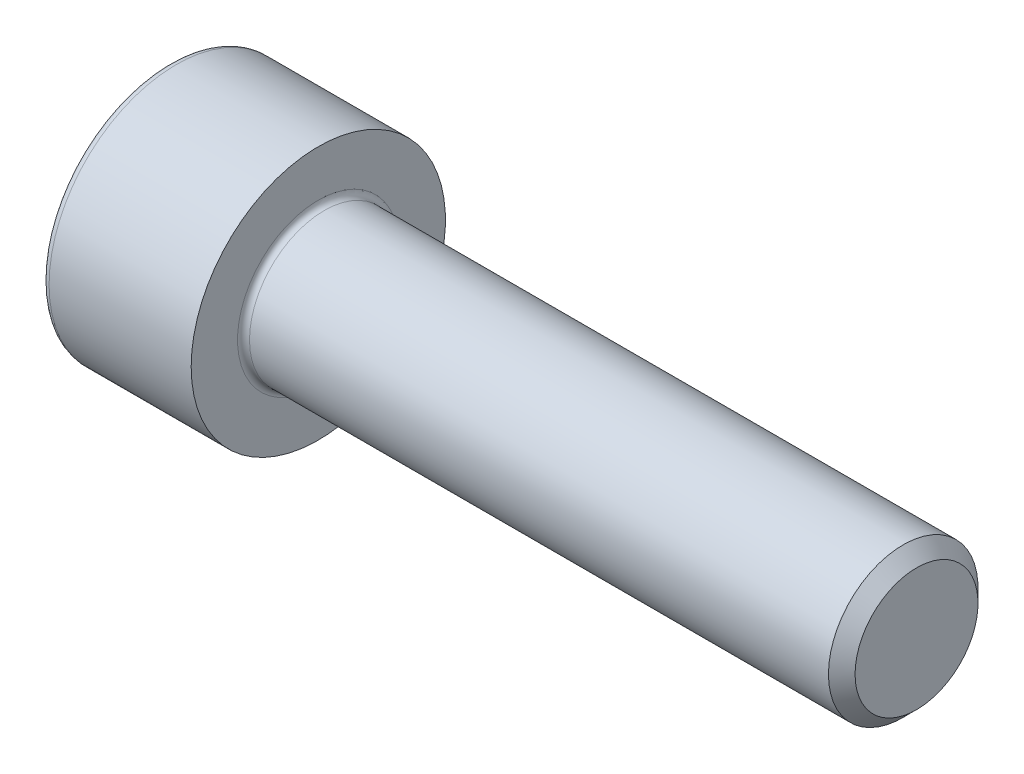
from build123d import *

# Parameters (mm, degrees)
FILLET1_R   = 0.2
FILLET2_R   = 0.25
HEX_2_DEPTH = 2.5


with BuildPart() as part:
    # BodySke → Base-Revolve (revolve)
    with BuildSketch(Plane.XY):
        Polygon((0, 0), (0, 4.25), (5, 4.25), (5, 2.5), (24.555, 2.5), (25, 2.055), (25, 0), align=None)
    revolve(axis=Axis((-31.75, 0, 0), (1, 0, 0)))

    # Fillet1
    fillet1_edges = [part.edges().sort_by_distance(p)[0] for p in [
        (5, -2.5, 0),
    ]]
    fillet(fillet1_edges, radius=FILLET1_R)

    # Fillet2
    fillet2_edges = [part.edges().sort_by_distance(p)[0] for p in [
        (0, -4.25, 0),
    ]]
    fillet(fillet2_edges, radius=FILLET2_R)

    # Sketch2 → Hex-PreBroach (revolve, cut)
    with BuildSketch(Plane.XY):
        Polygon((0, 2.042), (2.5, 2.042), (3.67894925, 0), (0, 0), align=None)
    revolve(axis=Axis((0, 0, 0), (1, 0, 0)), mode=Mode.SUBTRACT)

    # Sketch3 → Hex 2 (cut)
    with BuildSketch(Plane(origin=(0, 0, 0), x_dir=(0, 0.5, 0.866025404), z_dir=(-1, 0, 0))):
        Polygon((1.17894925, 2.042), (-1.17894925, 2.042), (-2.357898499, 0), (-1.17894925, -2.042), (1.17894925, -2.042), (2.357898499, 0), align=None)
    extrude(amount=-HEX_2_DEPTH, mode=Mode.SUBTRACT)


solid = part.part
